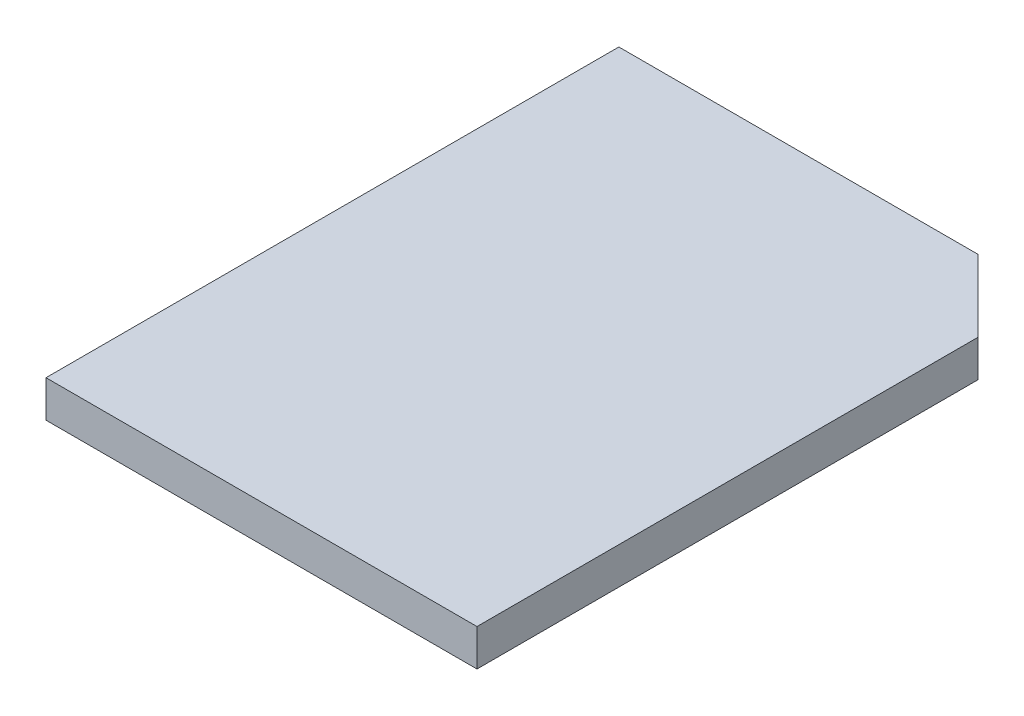
from build123d import *

# Parameters (mm, degrees)
SALIENTE_EXTRUIR1_DEPTH = 2.05


with BuildPart() as part:
    # Croquis1 → Saliente-Extruir1 (new body)
    with BuildSketch(Plane(origin=(0, 0, 0), x_dir=(1, 0, 0), z_dir=(0, 1, 0))):
        Polygon((20, 31.9), (24, 27.9), (24, 0), (0, 0), (0, 31.9), align=None)
    extrude(amount=SALIENTE_EXTRUIR1_DEPTH)


solid = part.part
